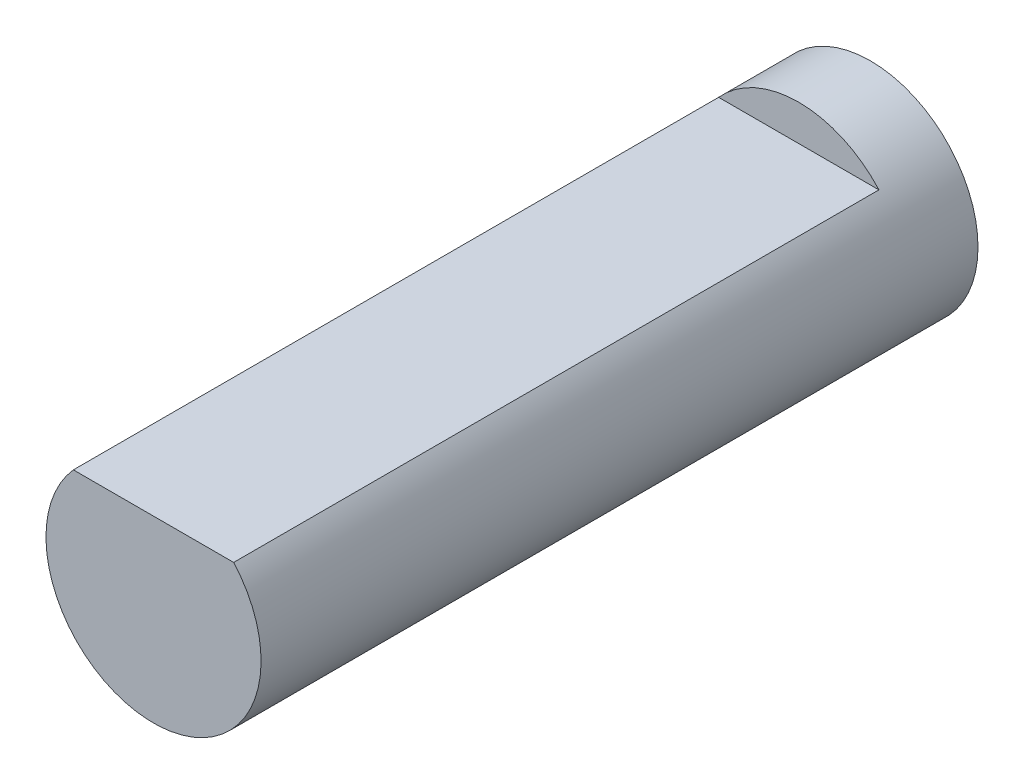
from build123d import *

# Parameters (mm, degrees)
SKETCH_1_R          = 1.5
EXTRUDE_1_DEPTH     = 10
CUT_EXTRUDE_1_DEPTH = 9


with BuildPart() as part:
    # 草图1 → 凸台-拉伸1 (new body)
    with BuildSketch(Plane.XY):
        Circle(SKETCH_1_R)
    extrude(amount=EXTRUDE_1_DEPTH)

    # 草图2 → 切除-拉伸1 (cut)
    with BuildSketch(Plane.XY.offset(10)):
        with BuildLine():
            Line((-1.118033989, 1), (1.118033989, 1))
            ThreePointArc((1.118033989, 1), (0, 1.5), (-1.118033989, 1))
        make_face()
    extrude(amount=-CUT_EXTRUDE_1_DEPTH, mode=Mode.SUBTRACT)


solid = part.part
